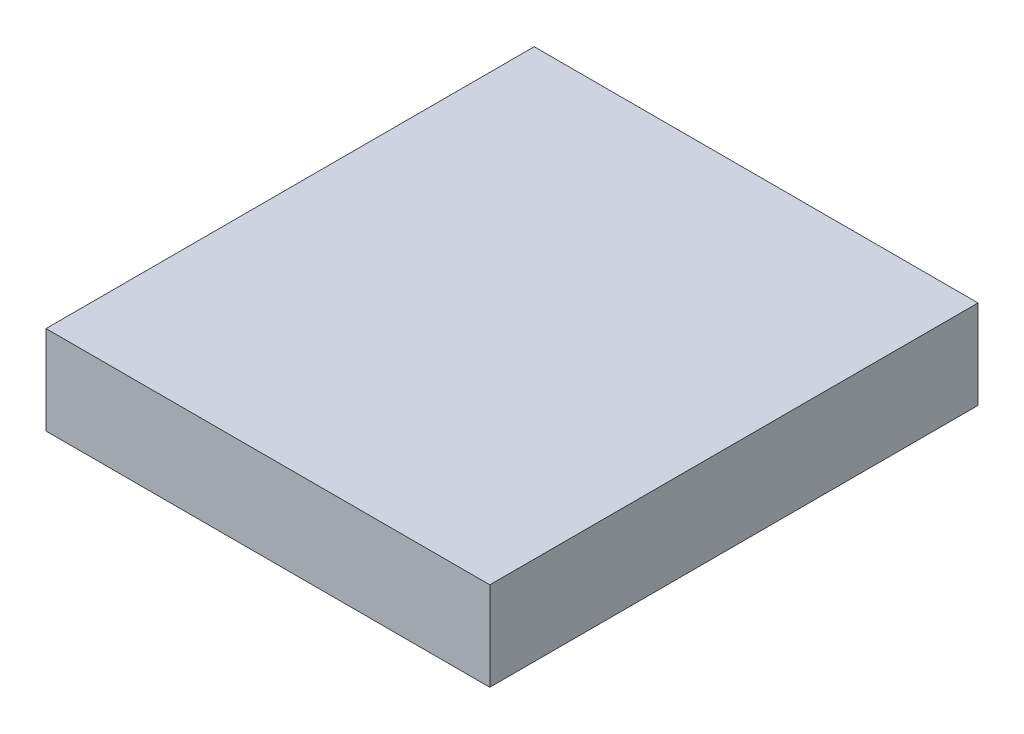
from build123d import *

# Parameters (mm, degrees)
SKETCH1_W           = 25
SKETCH1_H           = 27.5
BOSS_EXTRUDE4_DEPTH = 5


with BuildPart() as part:
    # Sketch1 → Boss-Extrude4 (new body)
    with BuildSketch(Plane(origin=(0, 0, 0), x_dir=(1, 0, 0), z_dir=(0, 1, 0))):
        Rectangle(SKETCH1_W, SKETCH1_H)
    extrude(amount=BOSS_EXTRUDE4_DEPTH)


solid = part.part
